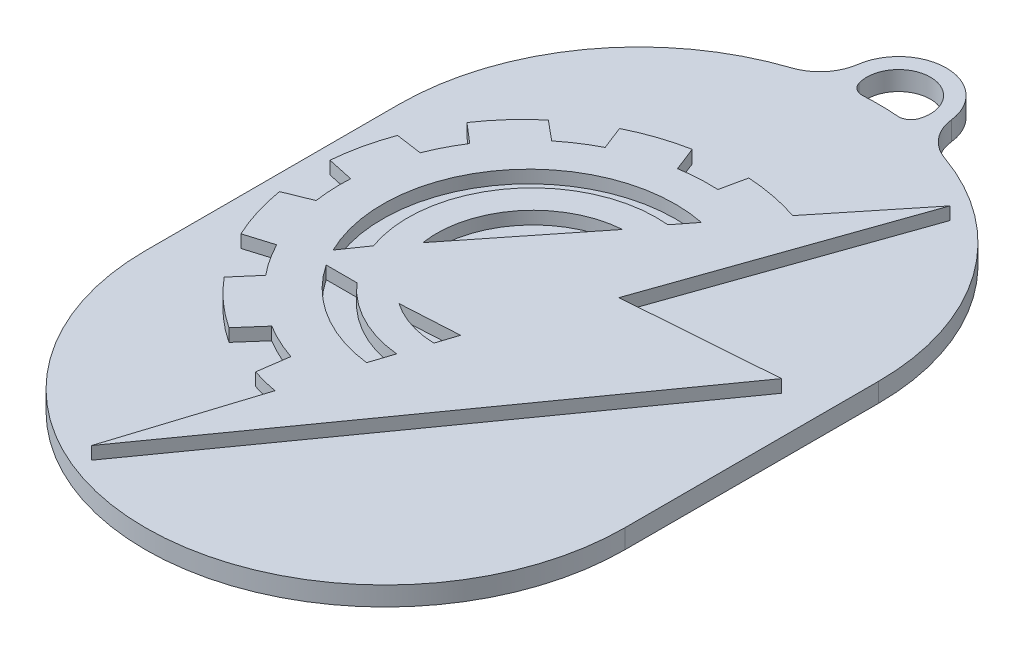
from build123d import *

# Parameters (mm, degrees)
RESSALTO_EXTRUS_O1_DEPTH = 2
RESSALTO_EXTRUS_O2_DEPTH = 3
ESBO_O4_R                = 7.5
ESBO_O4_R_2              = 5
RESSALTO_EXTRUS_O3_DEPTH = 3
FILETE4_R                = 7
FILETE5_R                = 2


with BuildPart() as part:
    # Esboço1 → Ressalto-extrusão1 (new body)
    with BuildSketch(Plane(origin=(0, 0, 0), x_dir=(1, 0, 0), z_dir=(0, 1, 0))):
        with BuildLine():
            Line((35.368861757, 1.558526937), (80.44962534, 64.847807407))
            Line((80.44962534, 64.847807407), (56.661079085, 63.08569287))
            Line((56.661079085, 63.08569287), (70.170623872, 101.558526937))
            Line((70.170623872, 101.558526937), (59.156651238, 87.901974937))
            ThreePointArc((59.156651238, 87.901974937), (54.928228331, 89.016089828), (50.590505915, 89.568336625))
            Line((50.590505915, 89.568336625), (49.725051843, 85.574021555))
            ThreePointArc((49.725051843, 85.574021555), (46.713204504, 85.564588761), (43.718646065, 85.242202157))
            Line((43.718646065, 85.242202157), (42.238652592, 89.029169094))
            ThreePointArc((42.238652592, 89.029169094), (37.869771908, 87.87748691), (33.696266723, 86.146780478))
            Line((33.696266723, 86.146780478), (35.147163269, 82.442381585))
            ThreePointArc((35.147163269, 82.442381585), (32.519355747, 80.921668866), (30.065315343, 79.134037687))
            Line((30.065315343, 79.134037687), (26.950821583, 81.70865653))
            ThreePointArc((26.950821583, 81.70865653), (23.697250977, 78.547127541), (20.902055839, 74.973911711))
            Line((20.902055839, 74.973911711), (23.978190261, 72.338887308))
            ThreePointArc((23.978190261, 72.338887308), (22.53348512, 69.828267118), (21.346972592, 67.18581093))
            Line((21.346972592, 67.18581093), (17.203178516, 67.77029239))
            ThreePointArc((17.203178516, 67.77029239), (15.945727998, 63.496158243), (15.268245742, 59.09270252))
            Line((15.268245742, 59.09270252), (19.408088551, 58.19571674))
            ThreePointArc((19.408088551, 58.19571674), (19.397757282, 55.347323146), (19.667469692, 52.511708923))
            Line((19.667469692, 52.511708923), (15.579228762, 50.857655899))
            ThreePointArc((15.579228762, 50.857655899), (16.629849838, 46.377497076), (18.286206869, 42.084233852))
            Line((18.286206869, 42.084233852), (22.590276365, 43.394445807))
            ThreePointArc((22.590276365, 43.394445807), (24.103796918, 40.801148677), (25.877857628, 38.378620441))
            Line((25.877857628, 38.378620441), (22.860818156, 34.873071796))
            ThreePointArc((22.860818156, 34.873071796), (26.252016309, 31.352757541), (30.120648437, 28.365028835))
            Line((30.120648437, 28.365028835), (33.261631483, 31.944309078))
            ThreePointArc((33.261631483, 31.944309078), (36.017323235, 30.464825168), (38.916576083, 29.291350585))
            Line((38.916576083, 29.291350585), (38.221393853, 24.458284446))
            ThreePointArc((38.221393853, 24.458284446), (40.249791444, 23.869041331), (42.311374517, 23.409172359))
            Line((42.311374517, 23.409172359), (35.368861757, 1.558526937))
        make_face()
        with BuildLine():
            Line((45.69219136, 34.421477023), (46.852612972, 37.978627375))
            ThreePointArc((46.852612972, 37.978627375), (39.82616677, 40.034244908), (34.05073918, 44.533238778))
            Line((34.05073918, 44.533238778), (29.228152417, 44.533238778))
            ThreePointArc((29.228152417, 44.533238778), (36.346609181, 37.664247561), (45.69219136, 34.421477023))
        make_face(mode=Mode.SUBTRACT)
        with BuildLine():
            Line((48.310484351, 42.358641567), (49.345616552, 45.531730412))
            Line((49.345616552, 45.531730412), (40.18411035, 45.009645625))
            ThreePointArc((40.18411035, 45.009645625), (44.056709172, 43.099915587), (48.310484351, 42.358641567))
        make_face(mode=Mode.SUBTRACT)
        with BuildLine():
            Line((33.776854594, 55.159722076), (47.668932581, 72.651374716))
            ThreePointArc((47.668932581, 72.651374716), (36.882518839, 66.95561957), (33.776854594, 55.159722076))
        make_face(mode=Mode.SUBTRACT)
        with BuildLine():
            Line((30.333100839, 50.857655899), (27.743535352, 47.116522773))
            ThreePointArc((27.743535352, 47.116522773), (30.159670342, 71.285374829), (52.90625945, 79.803813767))
            Line((52.90625945, 79.803813767), (50.5964095, 76.848744643))
            ThreePointArc((50.5964095, 76.848744643), (33.326207959, 69.418591815), (30.333100839, 50.857655899))
        make_face(mode=Mode.SUBTRACT)
    extrude(amount=RESSALTO_EXTRUS_O1_DEPTH)

    # Esboço3 → Ressalto-extrusão2 (add)
    with BuildSketch(Plane.XZ):
        with BuildLine():
            Line((11.084172824, -74.126509554), (11.084172824, -34.266887476))
            ThreePointArc((11.084172824, -34.266887476), (48.761301795, 3.410241496), (86.438430767, -34.266887476))
            Line((86.438430767, -34.266887476), (86.438430767, -74.126509554))
            ThreePointArc((86.438430767, -74.126509554), (48.761301795, -111.803638526), (11.084172824, -74.126509554))
        make_face()
    extrude(amount=RESSALTO_EXTRUS_O2_DEPTH)

    # Esboço4 → Ressalto-extrusão3 (add)
    with BuildSketch(Plane(origin=(0, 0, 0), x_dir=(1, 0, 0), z_dir=(0, 1, 0))):
        with Locations((49.129422152, 114.56282345)):
            Circle(ESBO_O4_R)
        with Locations((49.129422152, 114.56282345)):
            Circle(ESBO_O4_R_2, mode=Mode.SUBTRACT)
    extrude(amount=-RESSALTO_EXTRUS_O3_DEPTH)

    # Filete4
    filete4_edges = [part.edges().sort_by_distance(p)[0] for p in [
        (42.394905756, -1.5, -111.261870721),
        (55.802725528, -1.5, -111.139809858),
    ]]
    fillet(filete4_edges, radius=FILETE4_R)

    # Filete5
    filete5_edges = [part.edges().sort_by_distance(p)[0] for p in [
        (45.084410441, -1.5, -111.623796356),
        (53.120255788, -1.5, -111.550640374),
    ]]
    fillet(filete5_edges, radius=FILETE5_R)


solid = part.part
